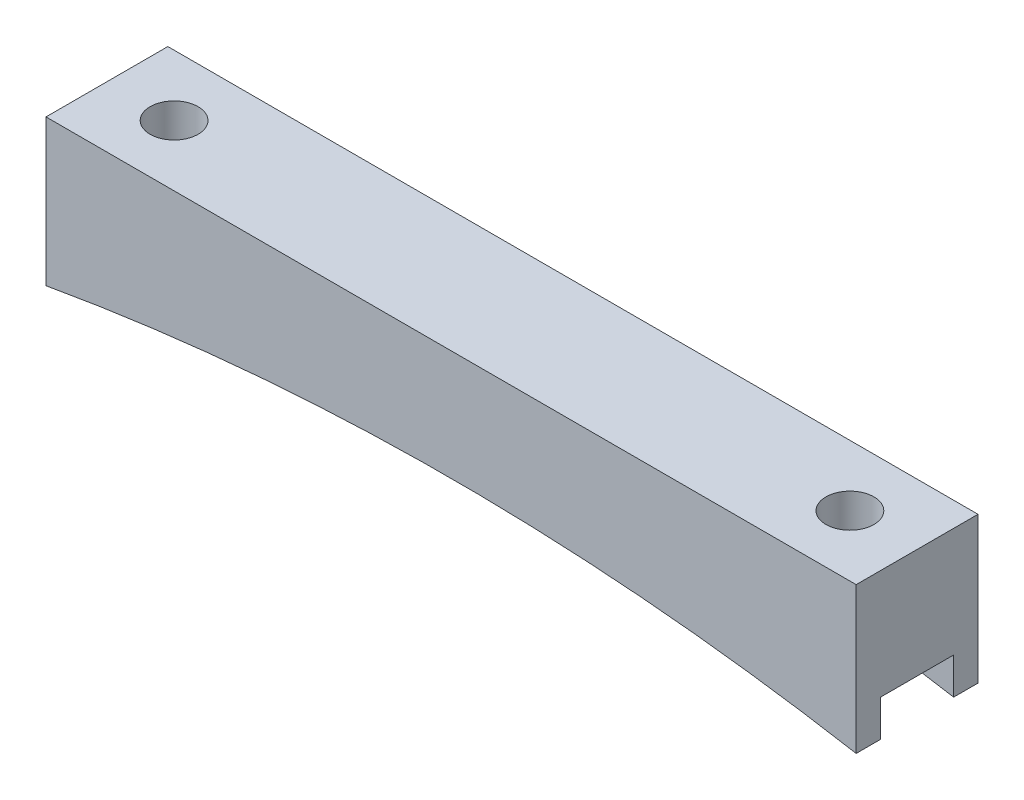
from build123d import *

# Parameters (mm, degrees)
BOSS_EXTRUDE1_DEPTH = 12.7
SKETCH2_R           = 2.5
CUT_EXTRUDE1_DEPTH  = 16.24
SKETCH3_W           = 7.62
SKETCH3_H           = 3.81
CUT_EXTRUDE2_DEPTH  = 85.4400001


with BuildPart() as part:
    # Sketch1 → Boss-Extrude1 (new body)
    with BuildSketch(Plane.XY):
        with BuildLine():
            Line((-42.22, 0), (42.22, 0))
            Line((42.22, 0), (42.22, -15.24))
            ThreePointArc((42.22, -15.24), (0, -11.517695923), (-42.22, -15.24))
            Line((-42.22, -15.24), (-42.22, 0))
        make_face()
    extrude(amount=BOSS_EXTRUDE1_DEPTH)

    # Sketch2 → Cut-Extrude1 (cut, through all)
    with BuildSketch(Plane(origin=(0, 0, 0), x_dir=(1, 0, 0), z_dir=(0, 1, 0))):
        with Locations((-35.22, -6.35)):
            Circle(SKETCH2_R)
        with Locations((35.22, -6.35)):
            Circle(SKETCH2_R)
    extrude(amount=-CUT_EXTRUDE1_DEPTH, mode=Mode.SUBTRACT)

    # Sketch3 → Cut-Extrude2 (cut, through all)
    with BuildSketch(Plane(origin=(42.22, 0, 0), x_dir=(0, 0, -1), z_dir=(1, 0, 0))):
        with Locations((-6.35, -13.335)):
            Rectangle(SKETCH3_W, SKETCH3_H)
    extrude(amount=-CUT_EXTRUDE2_DEPTH, mode=Mode.SUBTRACT)


solid = part.part
